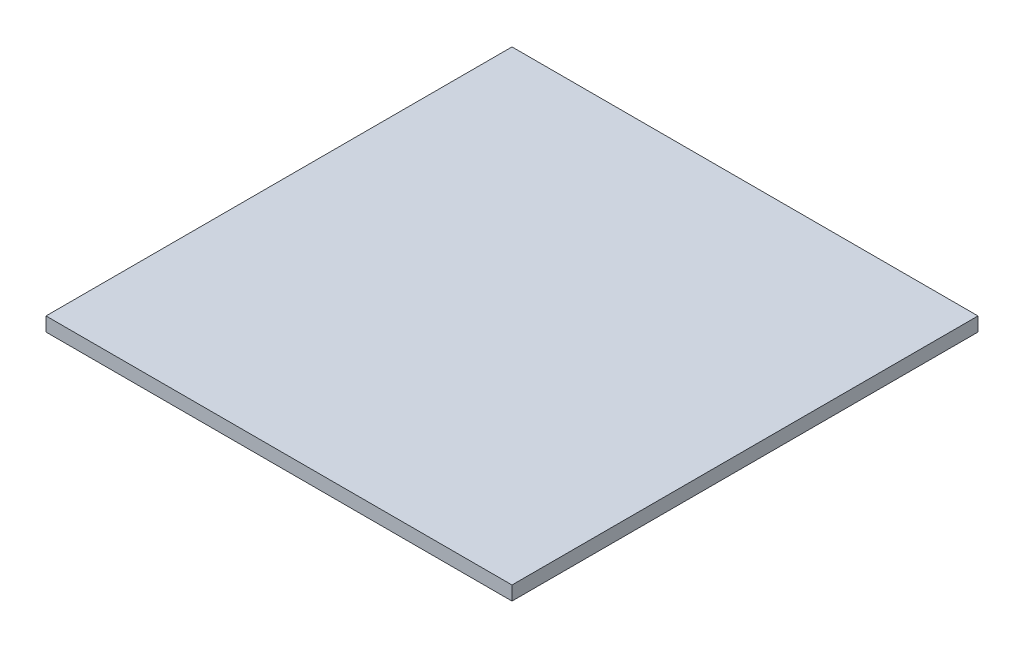
from build123d import *

# Parameters (mm, degrees)
ESQUISSE1_W        = 100
ESQUISSE1_H        = 100
BOSS_EXTRU_1_DEPTH = 3


with BuildPart() as part:
    # Esquisse1 → Boss.-Extru.1 (new body)
    with BuildSketch(Plane(origin=(0, 0, 0), x_dir=(1, 0, 0), z_dir=(0, 1, 0))):
        with Locations((50, 50)):
            Rectangle(ESQUISSE1_W, ESQUISSE1_H)
    extrude(amount=BOSS_EXTRU_1_DEPTH)


solid = part.part
